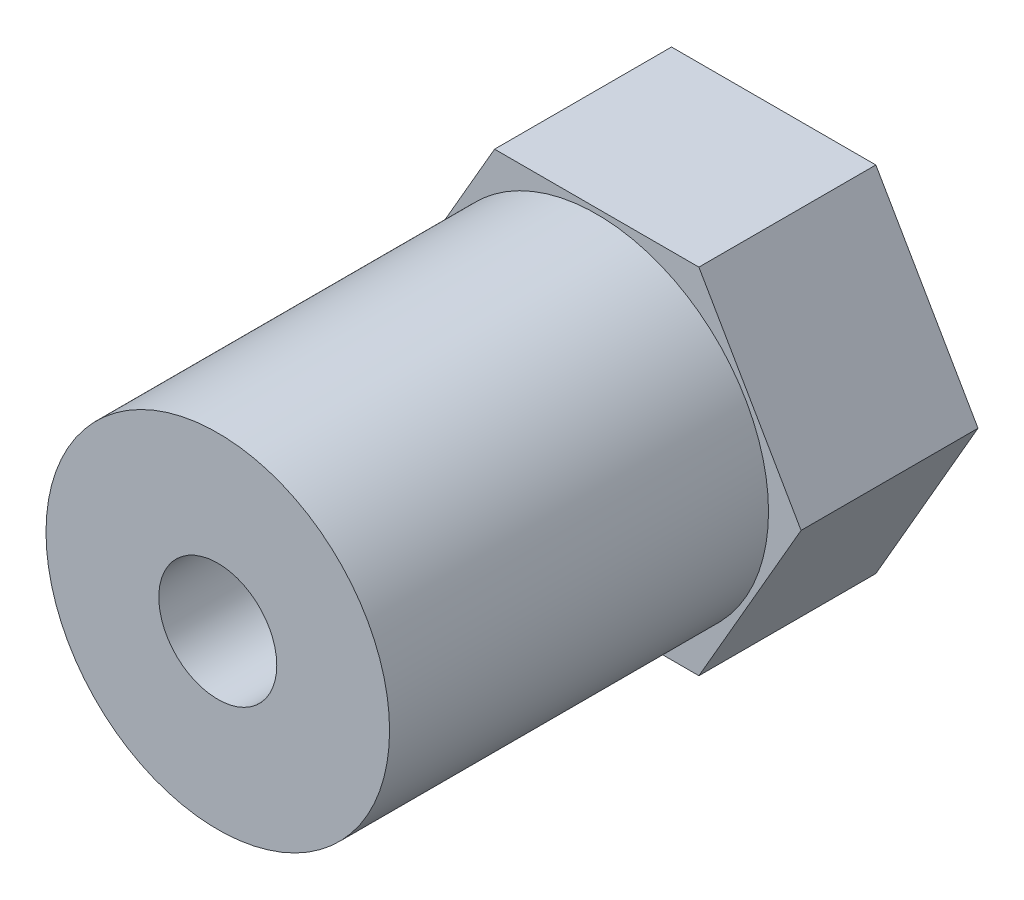
from build123d import *

# Parameters (mm, degrees)
SKETCH1_R           = 1.625
BOSS_EXTRUDE1_DEPTH = 6
SKETCH2_R           = 5.825
SKETCH2_R_2         = 2
BOSS_EXTRUDE2_DEPTH = 12.85


with BuildPart() as part:
    # Sketch1 → Boss-Extrude1 (new body)
    with BuildSketch(Plane.XY):
        Polygon((6.92820323, 0), (3.464101615, 6), (-3.464101615, 6), (-6.92820323, 0), (-3.464101615, -6), (3.464101615, -6), align=None)
        Circle(SKETCH1_R, mode=Mode.SUBTRACT)
    extrude(amount=BOSS_EXTRUDE1_DEPTH)

    # Sketch2 → Boss-Extrude2 (add)
    with BuildSketch(Plane.XY.offset(6)):
        Circle(SKETCH2_R)
        Circle(SKETCH2_R_2, mode=Mode.SUBTRACT)
    extrude(amount=BOSS_EXTRUDE2_DEPTH)


solid = part.part
